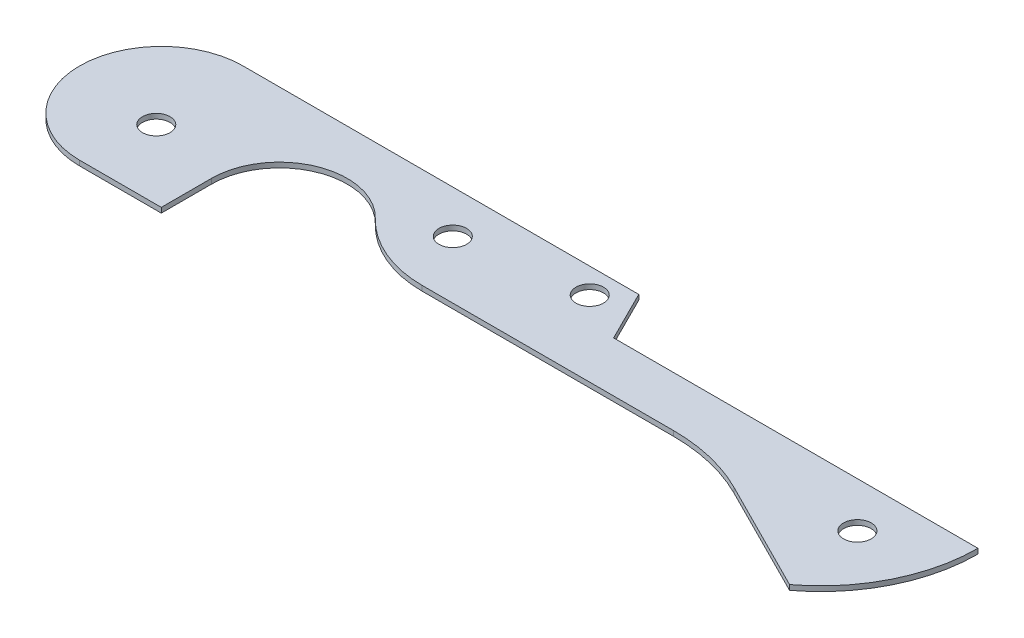
from build123d import *

# Parameters (mm, degrees)
BOSS_EXTRUDE1_DEPTH = 0.508
SKETCH2_R           = 1.397
CUT_EXTRUDE1_DEPTH  = 1.508


with BuildPart() as part:
    # Sketch1 → Boss-Extrude1 (new body)
    with BuildSketch(Plane(origin=(0, 0, 0), x_dir=(1, 0, 0), z_dir=(0, 1, 0))):
        with BuildLine():
            Line((0, 8.255), (40.005, 8.255))
            Line((40.005, 8.255), (42.545, 3.175))
            Line((42.545, 3.175), (79.375, 3.175))
            ThreePointArc((79.375, 3.175), (77.699031657, -3.924515829), (73.025, -9.525))
            Line((73.025, -9.525), (61.684438597, -3.808211822))
            ThreePointArc((61.684438597, -3.808211822), (57.789960212, -2.38631827), (53.672063189, -1.905))
            Line((53.672063189, -1.905), (28.272063189, -1.905))
            ThreePointArc((28.272063189, -1.905), (23.804442177, -0.995706369), (20.047648696, 1.5875))
            ThreePointArc((20.047648696, 1.5875), (12.544893378, 3.184008757), (8.255, -3.175))
            Line((8.255, -3.175), (8.255, -8.255))
            Line((8.255, -8.255), (0, -8.255))
            ThreePointArc((0, -8.255), (-8.255, 0), (0, 8.255))
        make_face()
    extrude(amount=BOSS_EXTRUDE1_DEPTH)

    # Sketch2 → Cut-Extrude1 (cut, through all)
    with BuildSketch(Plane(origin=(0, 0.508, 0), x_dir=(1, 0, 0), z_dir=(0, 1, 0))):
        with Locations((0.762, -1.27)):
            Circle(SKETCH2_R)
        with Locations((25.527, 3.937)):
            Circle(SKETCH2_R)
        with Locations((37.592, 5.715)):
            Circle(SKETCH2_R)
        with Locations((71.755, -1.397)):
            Circle(SKETCH2_R)
    extrude(amount=-CUT_EXTRUDE1_DEPTH, mode=Mode.SUBTRACT)


solid = part.part
